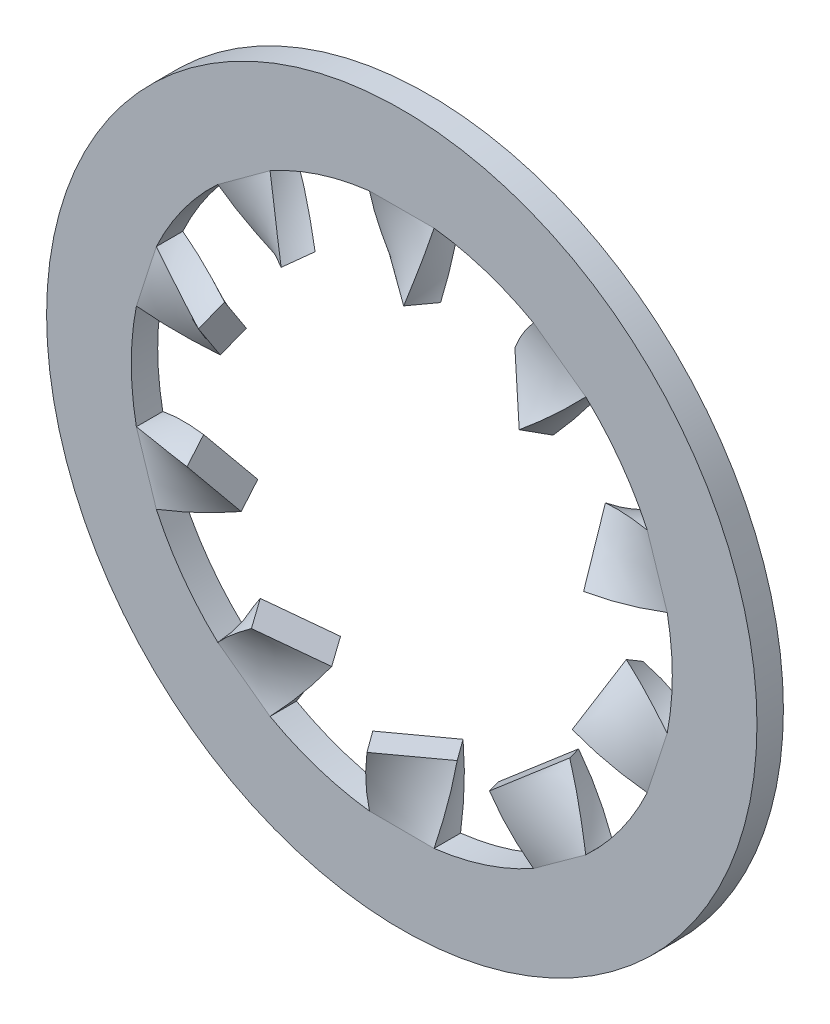
from build123d import *

# Parameters (mm, degrees)
SKETCH_1_R               = 10.75
SKETCH_1_R_2             = 8.18707288
EXTRUDE_1_DEPTH          = 0.8
SWEEP_1_PITCH            = 20
SWEEP_1_HEIGHT           = 2
SWEEP_1_RADIUS           = 1.056374657
SKETCH_3_W               = 1.955430814
SKETCH_3_H               = 0.8
PATTERN_CIRCULAR_1_COUNT = 10


with BuildPart() as part:
    # Эскиз1 → Бобышка-Вытянуть1 (new body)
    with BuildSketch(Plane.XY):
        Circle(SKETCH_1_R)
        Circle(SKETCH_1_R_2, mode=Mode.SUBTRACT)
        with BuildLine():
            ThreePointArc((0.977715407, 8.128482942), (0, 8.18707288), (-0.977715407, 8.128482942))
            Line((-0.977715407, 8.128482942), (0.977715407, 8.128482942))
        make_face()
        with BuildLine():
            ThreePointArc((5.568790776, 6.001394141), (4.812240699, 6.623481094), (3.986814017, 7.150767535))
            Line((3.986814017, 7.150767535), (5.568790776, 6.001394141))
        make_face()
        with BuildLine():
            ThreePointArc((8.032777346, 1.581976759), (7.786369012, 2.529944654), (7.428515993, 3.441701976))
            Line((7.428515993, 3.441701976), (8.032777346, 1.581976759))
        make_face()
        with BuildLine():
            ThreePointArc((7.428515993, -3.441701976), (7.786369012, -2.529944654), (8.032777346, -1.581976759))
            Line((8.032777346, -1.581976759), (7.428515993, -3.441701976))
        make_face()
        with BuildLine():
            ThreePointArc((3.986814017, -7.150767535), (4.812240699, -6.623481094), (5.568790776, -6.001394141))
            Line((5.568790776, -6.001394141), (3.986814017, -7.150767535))
        make_face()
        with BuildLine():
            Line((0.977715407, -8.128482942), (-0.977715407, -8.128482942))
            ThreePointArc((-0.977715407, -8.128482942), (0, -8.18707288), (0.977715407, -8.128482942))
        make_face()
        with BuildLine():
            Line((-3.986814017, -7.150767535), (-5.568790776, -6.001394141))
            ThreePointArc((-5.568790776, -6.001394141), (-4.812240699, -6.623481094), (-3.986814017, -7.150767535))
        make_face()
        with BuildLine():
            Line((-7.428515993, -3.441701976), (-8.032777346, -1.581976759))
            ThreePointArc((-8.032777346, -1.581976759), (-7.786369012, -2.529944654), (-7.428515993, -3.441701976))
        make_face()
        with BuildLine():
            Line((-8.032777346, 1.581976759), (-7.428515993, 3.441701976))
            ThreePointArc((-7.428515993, 3.441701976), (-7.786369012, 2.529944654), (-8.032777346, 1.581976759))
        make_face()
        with BuildLine():
            Line((-5.568790776, 6.001394141), (-3.986814017, 7.150767535))
            ThreePointArc((-3.986814017, 7.150767535), (-4.812240699, 6.623481094), (-5.568790776, 6.001394141))
        make_face()
    extrude(amount=EXTRUDE_1_DEPTH)

    # По траектории1: sweep along a helix
    with BuildLine() as sweep_1_path:
        Helix(SWEEP_1_PITCH, SWEEP_1_HEIGHT, SWEEP_1_RADIUS, center=(0, 8.128482942, 0.4), direction=(0, -1, 0))
    # Эскиз3 → По траектории1 (sweep)
    with BuildSketch(Plane.XZ.offset(-8.128482942)):
        with Locations((0, 0.4)):
            Rectangle(SKETCH_3_W, SKETCH_3_H)
    sweep_1 = sweep(path=sweep_1_path.line, is_frenet=True)

    # Круговой массив1: По траектории1 ×10 about axis
    pattern_circular_1_axis = Axis((0, 0, 0), (0, 0, -1))
    for i in range(1, PATTERN_CIRCULAR_1_COUNT):
        add(sweep_1.rotate(pattern_circular_1_axis, i * 360 / PATTERN_CIRCULAR_1_COUNT))


solid = part.part
